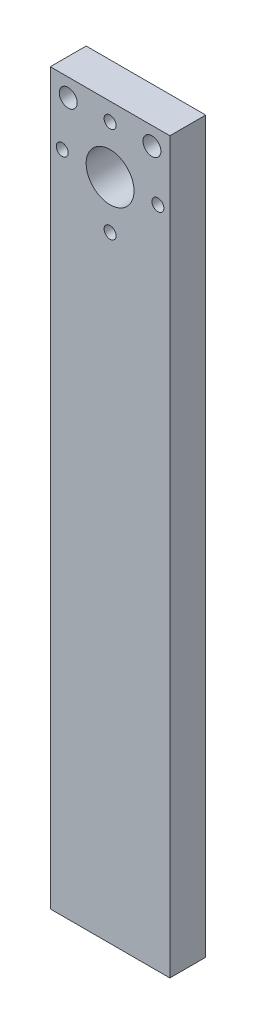
from build123d import *

# Parameters (mm, degrees)
ESQUISSE1_W             = 20
ESQUISSE1_H             = 122
BOSS_EXTRU_1_DEPTH      = 6
ESQUISSE2_R             = 4
ESQUISSE2_R_2           = 1
ESQUISSE2_R_3           = 1.5
ENL_V_MAT_EXTRU_1_DEPTH = 6


with BuildPart() as part:
    # Esquisse1 → Boss.-Extru.1 (new body)
    with BuildSketch(Plane.XY):
        with Locations((0, 23)):
            Rectangle(ESQUISSE1_W, ESQUISSE1_H)
    extrude(amount=BOSS_EXTRU_1_DEPTH)

    # Esquisse2 → Enlèv. mat.-Extru.1 (cut)
    with BuildSketch(Plane.XY.offset(6)):
        with Locations((0, 73)):
            Circle(ESQUISSE2_R)
        with Locations((0, 81)):
            Circle(ESQUISSE2_R_2)
        with Locations((-8, 73)):
            Circle(ESQUISSE2_R_2)
        with Locations((0, 65)):
            Circle(ESQUISSE2_R_2)
        with Locations((8, 73)):
            Circle(ESQUISSE2_R_2)
        with Locations((-7, 81)):
            Circle(ESQUISSE2_R_3)
        with Locations((7, 81)):
            Circle(ESQUISSE2_R_3)
    extrude(amount=-ENL_V_MAT_EXTRU_1_DEPTH, mode=Mode.SUBTRACT)


solid = part.part
